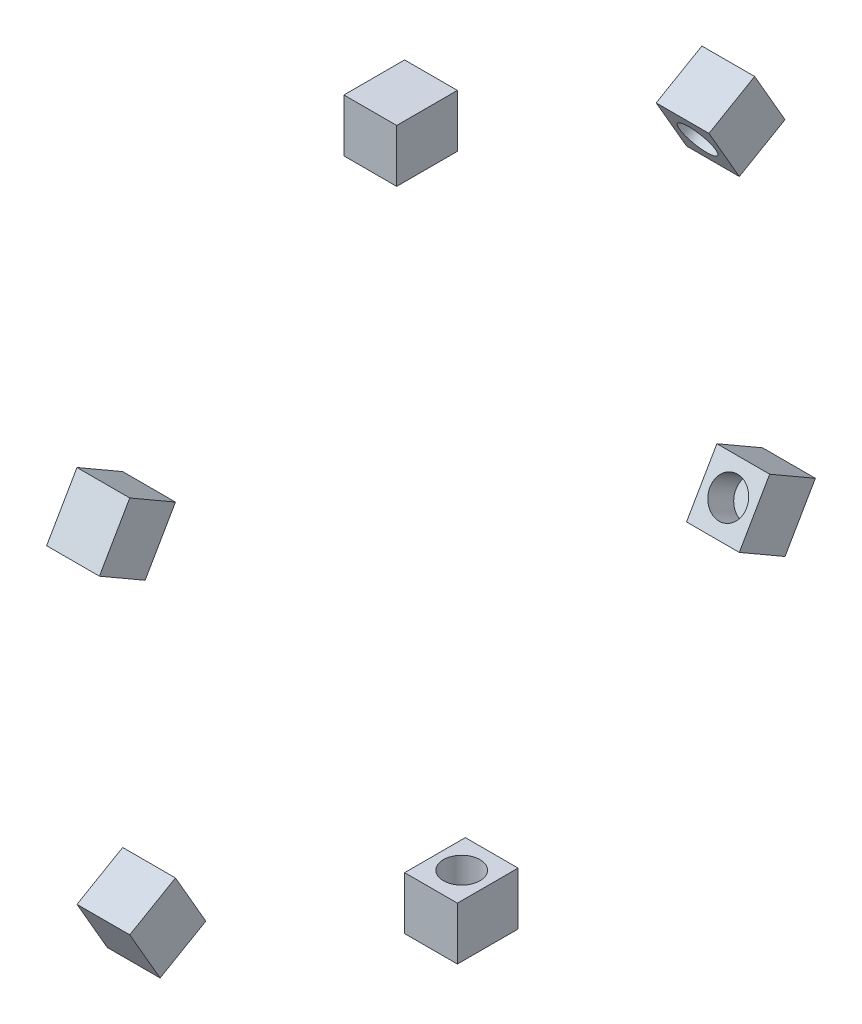
from build123d import *

# Parameters (mm, degrees)
SKETCH2_W           = 60
SKETCH2_H           = 60
BOSS_EXTRUDE1_DEPTH = 69
SKETCH4_R           = 20.797686061
CUT_EXTRUDE2_DEPTH  = 34
CIRPATTERN1_COUNT   = 6


with BuildPart() as part:
    # Sketch2 → Boss-Extrude1 (new body)
    with BuildSketch(Plane.XY):
        with Locations((-4.241285727, -1721.429159703)):
            Rectangle(SKETCH2_W, SKETCH2_H)
    extrude(amount=BOSS_EXTRUDE1_DEPTH)

    # Sketch4 → Cut-Extrude2 (cut)
    with BuildSketch(Plane.XZ.offset(1751.429159703)):
        with Locations((-4.241285727, 34.866773047)):
            Circle(SKETCH4_R)
    extrude(amount=-CUT_EXTRUDE2_DEPTH, mode=Mode.SUBTRACT)


with BuildPart() as cirpattern1_1:
    # CirPattern1: pattern copy
    add(part.part.rotate(Axis((0, -2121.429159703, 0), (1, 0, 0)), 1 * 360 / CIRPATTERN1_COUNT))


with BuildPart() as cirpattern1_2:
    # CirPattern1: pattern copy
    add(part.part.rotate(Axis((0, -2121.429159703, 0), (1, 0, 0)), 2 * 360 / CIRPATTERN1_COUNT))


with BuildPart() as cirpattern1_3:
    # CirPattern1: pattern copy
    add(part.part.rotate(Axis((0, -2121.429159703, 0), (1, 0, 0)), 3 * 360 / CIRPATTERN1_COUNT))


with BuildPart() as cirpattern1_4:
    # CirPattern1: pattern copy
    add(part.part.rotate(Axis((0, -2121.429159703, 0), (1, 0, 0)), 4 * 360 / CIRPATTERN1_COUNT))


with BuildPart() as cirpattern1_5:
    # CirPattern1: pattern copy
    add(part.part.rotate(Axis((0, -2121.429159703, 0), (1, 0, 0)), 5 * 360 / CIRPATTERN1_COUNT))


solid = Compound([part.part, cirpattern1_1.part, cirpattern1_2.part, cirpattern1_3.part, cirpattern1_4.part, cirpattern1_5.part])
